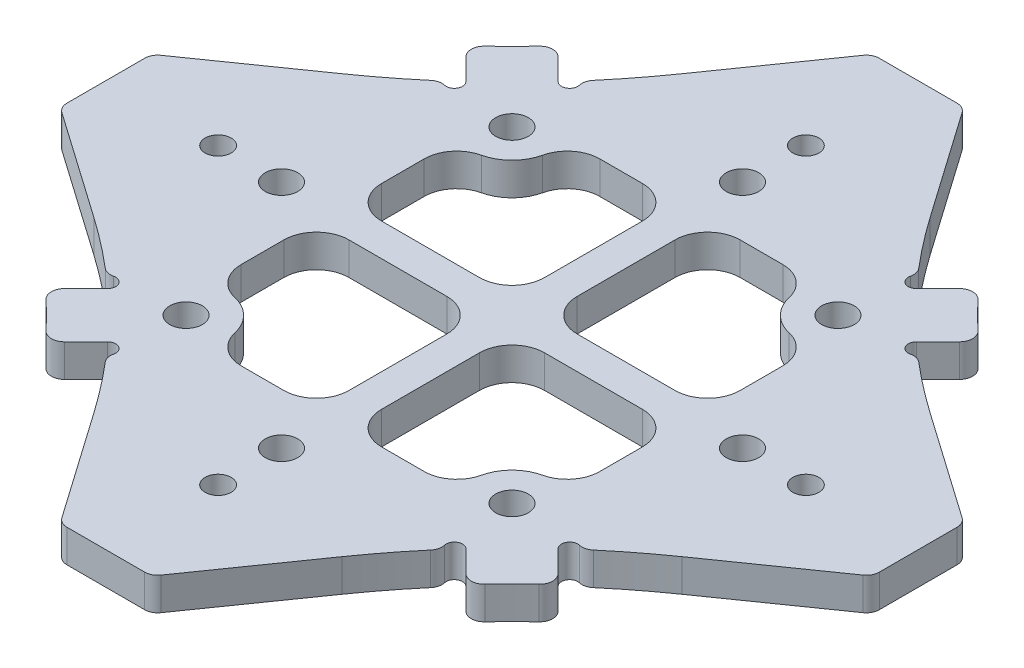
from build123d import *

# Parameters (mm, degrees)
EXTRUDE_1_DEPTH = 2
FILLET_1_R      = 0.8
FILLET_2_R      = 2


with BuildPart() as part:
    # 草图1 → 凸台-拉伸1 (new body)
    with BuildSketch(Plane(origin=(0, 0, 0), x_dir=(1, 0, 0), z_dir=(0, 1, 0))):
        with BuildLine():
            Line((7.612291547, 18.049472582), (2.800830153, 24.920951581))
            Line((2.800830153, 24.920951581), (0, 24.920951581))
            Line((0, 24.920951581), (0, 18.83122292))
            ThreePointArc((0, 18.83122292), (0.8, 18.03122292), (0, 17.23122292))
            Line((0, 17.23122292), (0, 15.142135624))
            ThreePointArc((0, 15.142135624), (1, 14.142135624), (0, 13.142135624))
            Line((0, 13.142135624), (0, 0))
            Line((0, 0), (1, 1))
            Line((1, 1), (1, 11))
            Line((1, 11), (7.708712153, 11))
            ThreePointArc((7.708712153, 11), (7.543556444, 9.535365676), (8.232233047, 8.232233047))
            Line((8.232233047, 8.232233047), (9.292893219, 9.292893219))
            ThreePointArc((9.292893219, 9.292893219), (9.292893219, 10.707106781), (10.707106781, 10.707106781))
            Line((10.707106781, 10.707106781), (14.28355698, 14.28355698))
            ThreePointArc((14.28355698, 14.28355698), (13.585117025, 14.999777476), (12.904898882, 15.733326007))
            Line((12.904898882, 15.733326007), (10.993394353, 13.821821478))
            ThreePointArc((10.993394353, 13.821821478), (10.286287572, 13.821821478), (10.286287572, 14.528928259))
            Line((10.286287572, 14.528928259), (10.32795627, 14.570596957))
            ThreePointArc((10.32795627, 14.570596957), (8.924937324, 16.274761415), (7.612291547, 18.049472582))
        make_face()
    extrude_1 = extrude(amount=EXTRUDE_1_DEPTH)

    # 镜向1: 凸台-拉伸1 across plane
    add(extrude_1.mirror(Plane(origin=(0, 2, 0), x_dir=(-0.707106781, 0, 0.707106781), z_dir=(0.707106781, 0, 0.707106781))))

    # 镜向2: part across plane


with BuildPart() as part_1:
    add(part.part)
    add(part.part.mirror(Plane(origin=(0, 2, 0), x_dir=(0, 0, 1), z_dir=(1, 0, 0))))

    # 镜向3: part across plane


with BuildPart() as part_2:
    add(part_1.part)
    add(part_1.part.mirror(Plane(origin=(0, 2, 0), x_dir=(1, 0, 0), z_dir=(0, 0, 1))))

    # 圆角1
    fillet_1_edges = [part_2.edges().sort_by_distance(p)[0] for p in [
        (14.570596957, 1, 10.32795627),
        (15.733326007, 1, 12.904898882),
        (10.32795627, 1, 14.570596957),
        (2.800830153, 1, 24.920951581),
        (-2.800830153, 1, 24.920951581),
        (-10.32795627, 1, 14.570596957),
        (-12.904898882, 1, 15.733326007),
        (-15.733326007, 1, 12.904898882),
        (-14.570596957, 1, 10.32795627),
        (-24.920951581, 1, 2.800830153),
        (-24.920951581, 1, -2.800830153),
        (-14.570596957, 1, -10.32795627),
        (-15.733326007, 1, -12.904898882),
        (-12.904898882, 1, -15.733326007),
        (-10.32795627, 1, -14.570596957),
        (-2.800830153, 1, -24.920951581),
        (2.800830153, 1, -24.920951581),
        (10.32795627, 1, -14.570596957),
        (12.904898882, 1, -15.733326007),
        (15.733326007, 1, -12.904898882),
        (14.570596957, 1, -10.32795627),
        (24.920951581, 1, -2.800830153),
        (24.920951581, 1, 2.800830153),
        (12.904898882, 1, 15.733326007),
    ]]
    fillet(fillet_1_edges, radius=FILLET_1_R)

    # 圆角2
    fillet_2_edges = [part_2.edges().sort_by_distance(p)[0] for p in [
        (-7.708712153, 1, -11),
        (-11, 1, -7.708712153),
        (-1, 1, -11),
        (-11, 1, -1),
        (-1, 1, -1),
        (7.708712153, 1, 11),
        (11, 1, 7.708712153),
        (1, 1, 11),
        (11, 1, 1),
        (1, 1, 1),
        (-1, 1, 11),
        (-7.708712153, 1, 11),
        (-1, 1, 1),
        (-11, 1, 7.708712153),
        (-11, 1, 1),
        (1, 1, -11),
        (1, 1, -1),
        (7.708712153, 1, -11),
        (11, 1, -7.708712153),
        (11, 1, -1),
    ]]
    fillet(fillet_2_edges, radius=FILLET_2_R)


solid = part_2.part
